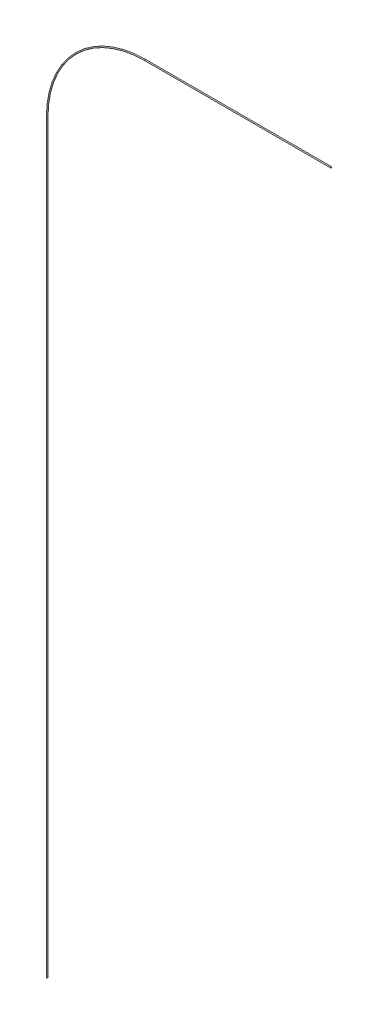
from build123d import *

# Parameters (mm, degrees)
SWEEP3_PROFILE_R = 0.127


with BuildPart() as part:
    # Sweep3: sweep along a path in Sketch1
    with BuildLine(Plane.XY) as sweep3_path:
        Line((32.335652054, 96.108050179), (-9.946450137, 96.108050179))
        ThreePointArc((-9.946450137, 96.108050179), (-25.778006638, 89.550404763), (-32.335652054, 73.718848262))
        Line((-32.335652054, 73.718848262), (-32.335652054, -96.108050179))
    # Sweep3 profile (on start of the path) → Sweep3 (sweep)
    with BuildSketch(Plane(origin=(32.335652054, 96.108050179, 0), x_dir=(0, 0, -1), z_dir=(-1, 0, 0))):
        Circle(SWEEP3_PROFILE_R)
    sweep(path=sweep3_path.line)


solid = part.part
